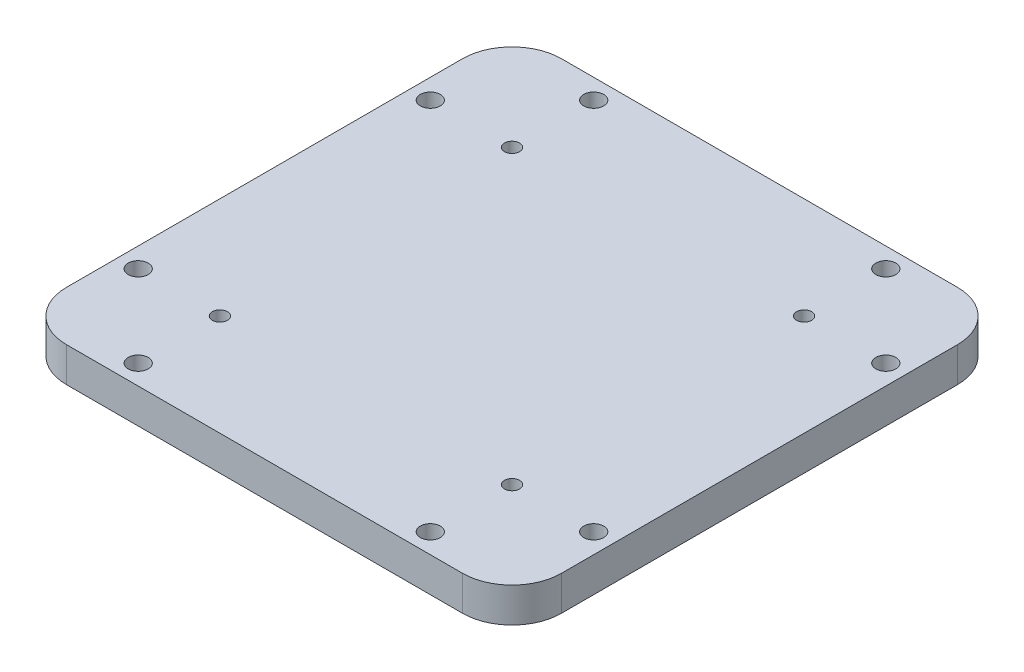
from build123d import *

# Parameters (mm, degrees)
SKETCH_1_W          = 100
SKETCH_1_H          = 100
EXTRUDE_1_DEPTH     = 7
FILLET_1_R          = 10
SKETCH_2_R          = 1.52
SKETCH_2_R_2        = 2.02
CUT_EXTRUDE_2_DEPTH = 13


with BuildPart() as part:
    # 草图1 → 凸台-拉伸1 (new body)
    with BuildSketch(Plane(origin=(0, 0, 0), x_dir=(1, 0, 0), z_dir=(0, 1, 0))):
        with Locations((50, 50)):
            Rectangle(SKETCH_1_W, SKETCH_1_H)
    extrude(amount=EXTRUDE_1_DEPTH)

    # 圆角1
    fillet_1_edges = [part.edges().sort_by_distance(p)[0] for p in [
        (0, 3.5, 0),
        (0, 3.5, -100),
        (100, 3.5, -100),
        (100, 3.5, 0),
    ]]
    fillet(fillet_1_edges, radius=FILLET_1_R)

    # 草图2 → 切除-拉伸2 (cut)
    with BuildSketch(Plane(origin=(0, 7, 0), x_dir=(1, 0, 0), z_dir=(0, 1, 0))):
        with BuildLine():
            ThreePointArc((22.02, 79.5), (21.574802307, 80.574802307), (20.5, 81.02))
            Line((20.5, 81.02), (20.5, 79.5))
            Line((20.5, 79.5), (18.98, 79.5))
            ThreePointArc((18.98, 79.5), (20.5, 77.98), (22.02, 79.5))
        make_face()
        with BuildLine():
            Line((20.5, 79.5), (20.5, 81.02))
            ThreePointArc((20.5, 81.02), (19.425197693, 80.574802307), (18.98, 79.5))
            Line((18.98, 79.5), (20.5, 79.5))
        make_face()
        with BuildLine():
            ThreePointArc((6.02, 79.5), (4, 81.52), (1.98, 79.5))
            Line((1.98, 79.5), (4, 79.5))
            Line((4, 79.5), (6.02, 79.5))
        make_face()
        with BuildLine():
            Line((4, 79.5), (1.98, 79.5))
            ThreePointArc((1.98, 79.5), (4, 77.48), (6.02, 79.5))
            Line((6.02, 79.5), (4, 79.5))
        make_face()
        with BuildLine():
            ThreePointArc((22.52, 96), (21.928355698, 97.428355698), (20.5, 98.02))
            Line((20.5, 98.02), (20.5, 96))
            Line((20.5, 96), (20.5, 93.98))
            ThreePointArc((20.5, 93.98), (21.928355698, 94.571644302), (22.52, 96))
        make_face()
        with BuildLine():
            Line((20.5, 96), (20.5, 98.02))
            ThreePointArc((20.5, 98.02), (18.48, 96), (20.5, 93.98))
            Line((20.5, 93.98), (20.5, 96))
        make_face()
        with Locations((79.5, 79.5)):
            Circle(SKETCH_2_R)
        with Locations((79.5, 96)):
            Circle(SKETCH_2_R_2)
        with Locations((96, 79.5)):
            Circle(SKETCH_2_R_2)
        with Locations((79.5, 20.5)):
            Circle(SKETCH_2_R)
        with Locations((96, 20.5)):
            Circle(SKETCH_2_R_2)
        with Locations((79.5, 4)):
            Circle(SKETCH_2_R_2)
        with Locations((20.5, 20.5)):
            Circle(SKETCH_2_R)
        with Locations((4, 20.5)):
            Circle(SKETCH_2_R_2)
        with Locations((20.5, 4)):
            Circle(SKETCH_2_R_2)
    extrude(amount=-CUT_EXTRUDE_2_DEPTH, mode=Mode.SUBTRACT)


solid = part.part
